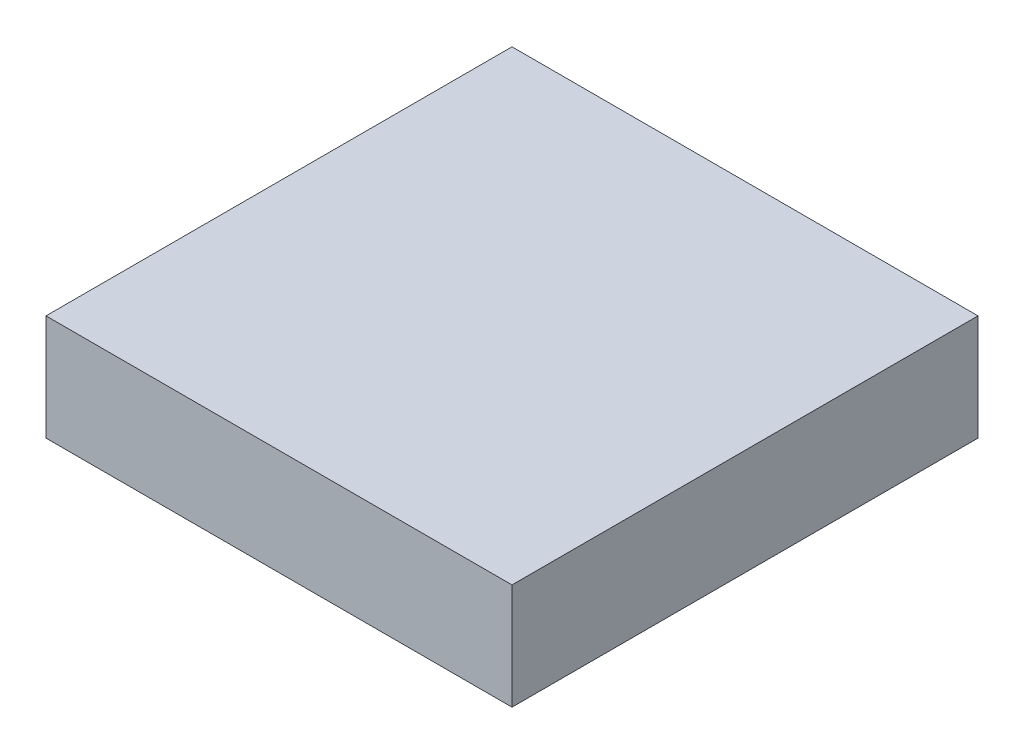
from build123d import *

# Parameters (mm, degrees)
SKETCH1_W           = 55.88
SKETCH1_H           = 55.88
BOSS_EXTRUDE1_DEPTH = 6.35


with BuildPart() as part:
    # Sketch1 → Boss-Extrude1 (new body, symmetric)
    with BuildSketch(Plane(origin=(0, 0, 0), x_dir=(1, 0, 0), z_dir=(0, 1, 0))):
        Rectangle(SKETCH1_W, SKETCH1_H)
    extrude(amount=BOSS_EXTRUDE1_DEPTH, both=True)


solid = part.part
